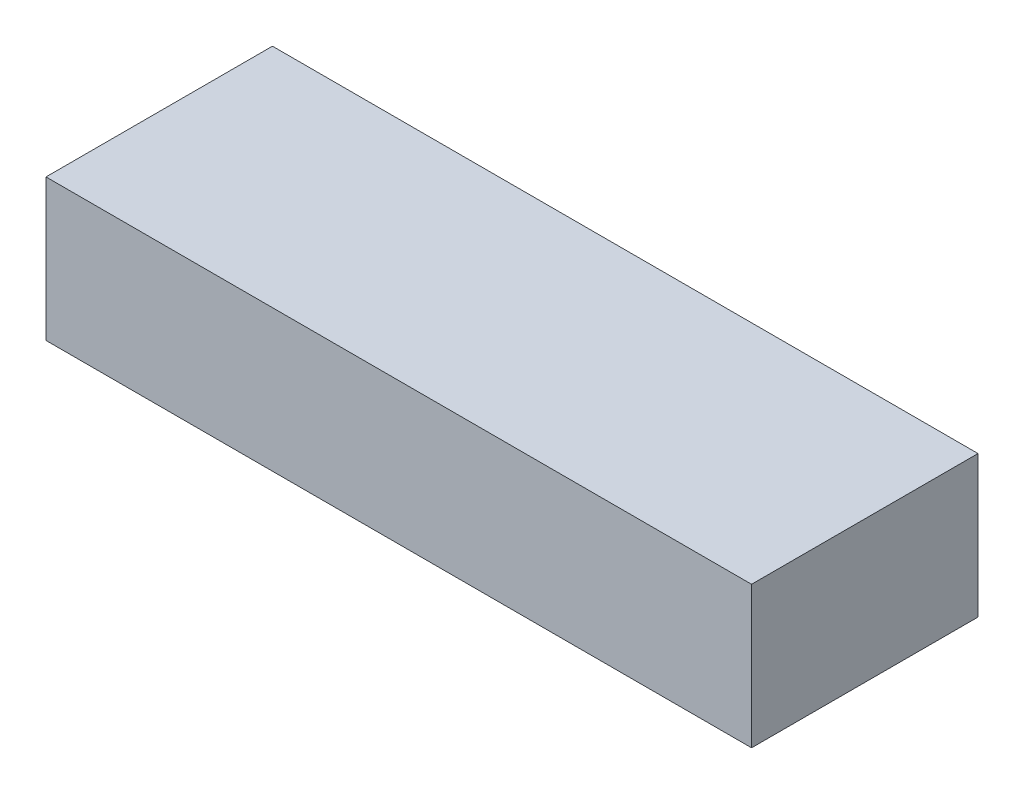
from build123d import *

# Parameters (mm, degrees)
SKETCH1_W           = 106.84
SKETCH1_H           = 34.29
BOSS_EXTRUDE1_DEPTH = 21.45


with BuildPart() as part:
    # Sketch1 → Boss-Extrude1 (new body)
    with BuildSketch(Plane(origin=(0, 0, 0), x_dir=(1, 0, 0), z_dir=(0, 1, 0))):
        with Locations((18.744775691, -7.420810356)):
            Rectangle(SKETCH1_W, SKETCH1_H)
    extrude(amount=BOSS_EXTRUDE1_DEPTH)


solid = part.part
